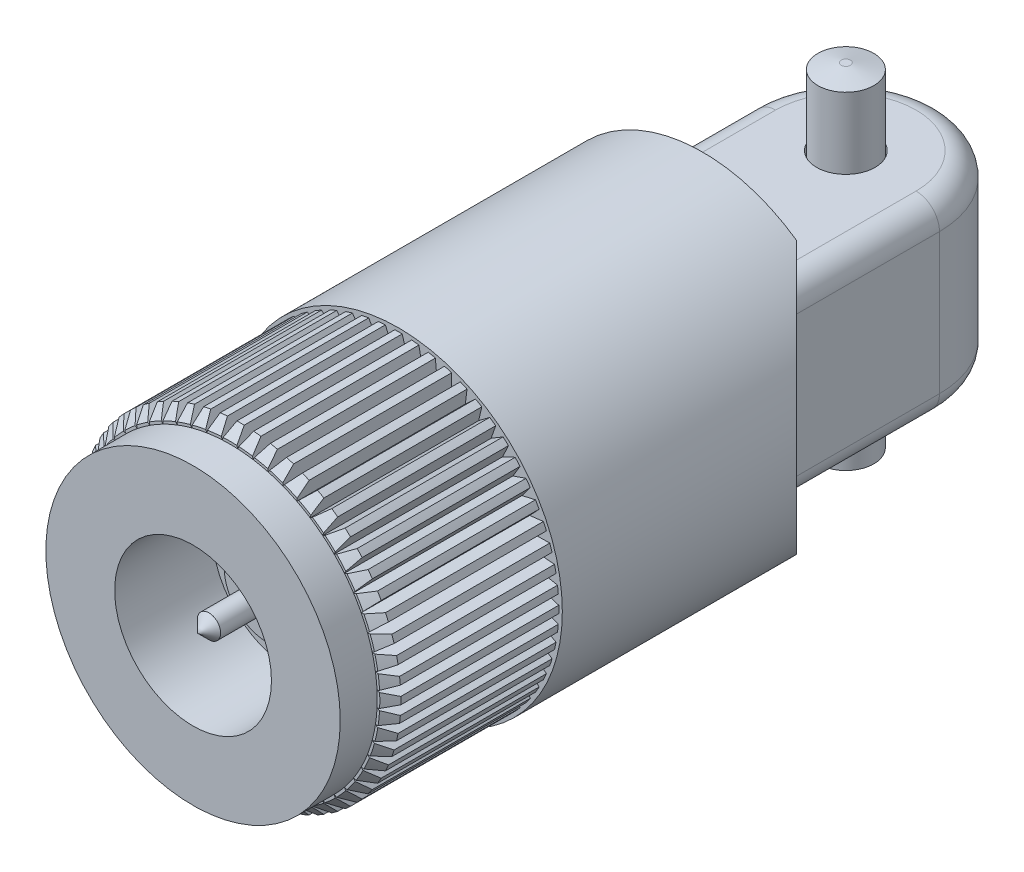
from build123d import *

# Parameters (mm, degrees)
SKETCH1_R                = 7
BOSS_EXTRUDE1_DEPTH      = 13
CUT_EXTRUDE1_DEPTH       = 13
CUT_EXTRUDE1_DEPTH_BACK  = 13
SKETCH3_R                = 1.25
BOSS_EXTRUDE2_DEPTH      = 4
BOSS_EXTRUDE2_DEPTH_BACK = 4
SKETCH4_R                = 6.85
BOSS_EXTRUDE3_DEPTH      = 7.2
SKETCH5_R                = 6.29
BOSS_EXTRUDE4_DEPTH      = 1.58
CHAMFER1_SIZE            = 0.45
CUT_EXTRUDE2_DEPTH       = 7.2
CIRPATTERN1_COUNT        = 60
FILLET1_R                = 1
SKETCH7_R                = 3.35
CUT_EXTRUDE3_DEPTH       = 4.18
SKETCH8_R                = 1.85
BOSS_EXTRUDE5_DEPTH      = 1
SKETCH9_R                = 0.5
BOSS_EXTRUDE6_DEPTH      = 3
CHAMFER2_SIZE            = 0.5
SKETCH10_R               = 1.194401024
BOSS_EXTRUDE7_DEPTH      = 7.25
BOSS_EXTRUDE7_DEPTH_BACK = 7.25
CHAMFER3_SIZE            = 0.25
CHAMFER3_SIZE2           = 1
CHAMFER4_SIZE            = 1
CHAMFER4_SIZE2           = 0.25


with BuildPart() as part:
    # Sketch1 → Boss-Extrude1 (new body)
    with BuildSketch(Plane.XY):
        Circle(SKETCH1_R)
    extrude(amount=BOSS_EXTRUDE1_DEPTH)

    # Sketch2 → Cut-Extrude1 (cut, two sides)
    with BuildSketch(Plane(origin=(0, 0, 0), x_dir=(1, 0, 0), z_dir=(0, 1, 0))) as cut_extrude1_sk:
        Polygon((4, 0), (7, -3), (7, 0), align=None)
    extrude(amount=CUT_EXTRUDE1_DEPTH, mode=Mode.SUBTRACT)
    extrude(cut_extrude1_sk.sketch, amount=-CUT_EXTRUDE1_DEPTH_BACK, mode=Mode.SUBTRACT)

    # Sketch3 → Boss-Extrude2 (add, two sides)
    with BuildSketch(Plane(origin=(0, 0, 0), x_dir=(1, 0, 0), z_dir=(0, 1, 0))) as boss_extrude2_sk:
        with BuildLine():
            Line((4, 0), (4, 6.115994453))
            ThreePointArc((4, 6.115994453), (0, 10.115994453), (-4, 6.115994453))
            Line((-4, 6.115994453), (-4, 0))
            Line((-4, 0), (4, 0))
        make_face()
        with Locations((0, 6.115994453)):
            Circle(SKETCH3_R, mode=Mode.SUBTRACT)
    extrude(amount=BOSS_EXTRUDE2_DEPTH)
    extrude(boss_extrude2_sk.sketch, amount=-BOSS_EXTRUDE2_DEPTH_BACK)

    # Sketch4 → Boss-Extrude3 (add)
    with BuildSketch(Plane.XY.offset(13)):
        Circle(SKETCH4_R)
    extrude(amount=BOSS_EXTRUDE3_DEPTH)

    # Sketch5 → Boss-Extrude4 (add)
    with BuildSketch(Plane.XY.offset(20.2)):
        Circle(SKETCH5_R)
    extrude(amount=BOSS_EXTRUDE4_DEPTH)

    # Chamfer1
    chamfer1_edges = [part.edges().sort_by_distance(p)[0] for p in [
        (-6.85, 0, 20.2),
    ]]
    chamfer(chamfer1_edges, length=CHAMFER1_SIZE)

    # Sketch6 → Cut-Extrude2 (cut)
    with BuildSketch(Plane.XY.offset(13)):
        Polygon((0, 6.85), (0.155348515, 6.85), (0.329193165, 6.281379774), (0.561522473, 6.828713325), (0.716019973, 6.812474983), (0.766835244, 7.295949985), (0, 7.336138118), align=None)
    cut_extrude2 = extrude(amount=CUT_EXTRUDE2_DEPTH, mode=Mode.SUBTRACT)

    # CirPattern1: Cut-Extrude2 ×60 about axis
    cirpattern1_axis = Axis((0, 0, 0), (0, 0, 1))
    for i in range(1, CIRPATTERN1_COUNT):
        add(cut_extrude2.rotate(cirpattern1_axis, i * 360 / CIRPATTERN1_COUNT), mode=Mode.SUBTRACT)

    # Fillet1
    fillet1_edges = [part.edges().sort_by_distance(p)[0] for p in [
        (4, -4, -3.057997226),
        (-4, -4, -3.057997226),
        (-4, 4, -3.057997226),
        (0, 4, -10.115994453),
        (0, -4, -10.115994453),
        (4, 4, -3.057997226),
    ]]
    fillet(fillet1_edges, radius=FILLET1_R)

    # Sketch7 → Cut-Extrude3 (cut)
    with BuildSketch(Plane.XY.offset(21.78)):
        Circle(SKETCH7_R)
    extrude(amount=-CUT_EXTRUDE3_DEPTH, mode=Mode.SUBTRACT)

    # Sketch8 → Boss-Extrude5 (add)
    with BuildSketch(Plane.XY.offset(17.6)):
        Circle(SKETCH8_R)
    extrude(amount=BOSS_EXTRUDE5_DEPTH)

    # Sketch9 → Boss-Extrude6 (add)
    with BuildSketch(Plane.XY.offset(18.6)):
        Circle(SKETCH9_R)
    extrude(amount=BOSS_EXTRUDE6_DEPTH)

    # Chamfer2
    chamfer2_edges = [part.edges().sort_by_distance(p)[0] for p in [
        (-0.5, 0, 21.6),
    ]]
    chamfer(chamfer2_edges, length=CHAMFER2_SIZE)


with BuildPart() as body_2:
    # Sketch10 → Boss-Extrude7 (new body, two sides)
    with BuildSketch(Plane(origin=(0, 0, 0), x_dir=(1, 0, 0), z_dir=(0, 1, 0))) as boss_extrude7_sk:
        with Locations((0, 6.115994453)):
            Circle(SKETCH10_R)
    extrude(amount=BOSS_EXTRUDE7_DEPTH)
    extrude(boss_extrude7_sk.sketch, amount=-BOSS_EXTRUDE7_DEPTH_BACK)

    # Chamfer3
    chamfer3_edges = [body_2.edges().sort_by_distance(p)[0] for p in [
        (-1.194401024, 7.25, -6.115994453),
    ]]
    chamfer3_side = [body_2.faces().sort_by_distance(p)[0] for p in [
        (-1.194401024, 3.625, -6.115994453),
    ]]
    chamfer(chamfer3_edges, length=CHAMFER3_SIZE, length2=CHAMFER3_SIZE2, reference=chamfer3_side[0])

    # Chamfer4
    chamfer4_edges = [body_2.edges().sort_by_distance(p)[0] for p in [
        (-1.194401024, -7.25, -6.115994453),
    ]]
    chamfer4_side = [body_2.faces().sort_by_distance(p)[0] for p in [
        (0, -7.25, -6.115994453),
    ]]
    chamfer(chamfer4_edges, length=CHAMFER4_SIZE, length2=CHAMFER4_SIZE2, reference=chamfer4_side[0])


solid = Compound([part.part, body_2.part])
